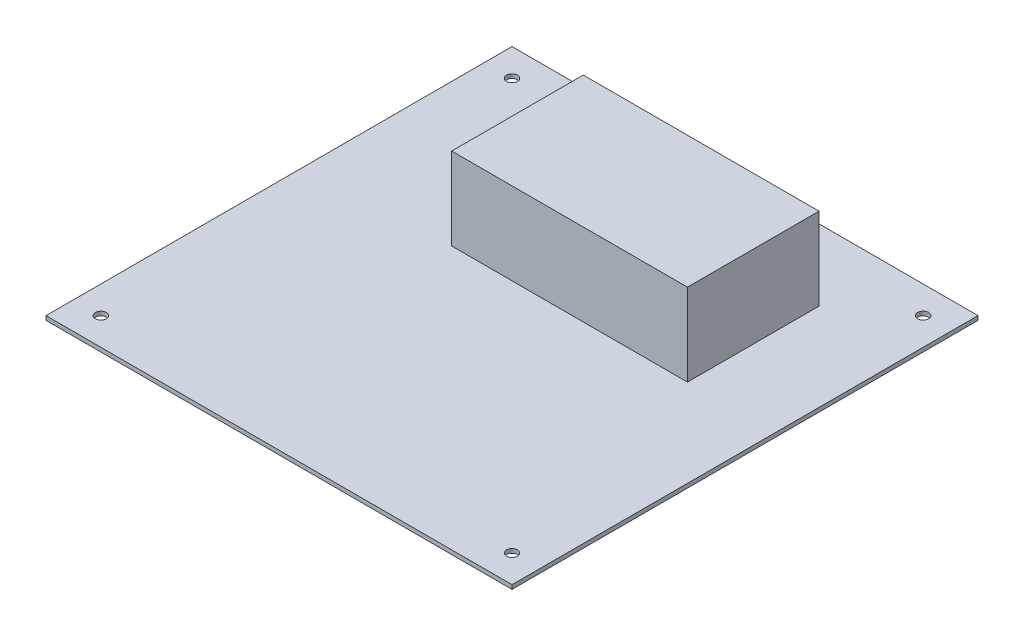
from build123d import *

# Parameters (mm, degrees)
SKETCH1_W           = 170
SKETCH1_H           = 170
SKETCH1_R           = 2
BOSS_EXTRUDE1_DEPTH = 1.5
SKETCH2_W           = 86
SKETCH2_H           = 48
BOSS_EXTRUDE2_DEPTH = 30


with BuildPart() as part:
    # Sketch1 → Boss-Extrude1 (new body)
    with BuildSketch(Plane(origin=(0, 0, 0), x_dir=(1, 0, 0), z_dir=(0, 1, 0))):
        Rectangle(SKETCH1_W, SKETCH1_H)
        with Locations((-75, -75)):
            Circle(SKETCH1_R, mode=Mode.SUBTRACT)
        with Locations((75, -75)):
            Circle(SKETCH1_R, mode=Mode.SUBTRACT)
        with Locations((75, 75)):
            Circle(SKETCH1_R, mode=Mode.SUBTRACT)
        with Locations((-75, 75)):
            Circle(SKETCH1_R, mode=Mode.SUBTRACT)
    extrude(amount=BOSS_EXTRUDE1_DEPTH)

    # Sketch2 → Boss-Extrude2 (add)
    with BuildSketch(Plane(origin=(0, 1.5, 0), x_dir=(1, 0, 0), z_dir=(0, 1, 0))):
        with Locations((10, 35)):
            Rectangle(SKETCH2_W, SKETCH2_H)
    extrude(amount=BOSS_EXTRUDE2_DEPTH)


solid = part.part
